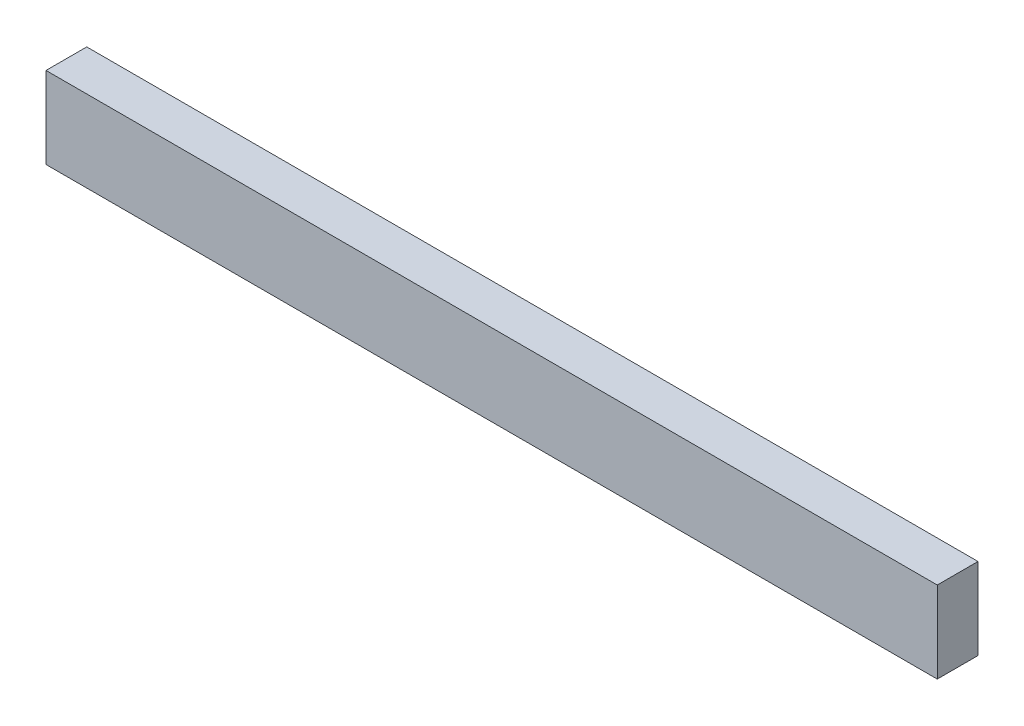
from build123d import *

# Parameters (mm, degrees)
SKETCH1_W           = 555.625
SKETCH1_H           = 50.8
BOSS_EXTRUDE1_DEPTH = 25.4


with BuildPart() as part:
    # Sketch1 → Boss-Extrude1 (new body)
    with BuildSketch(Plane.XY):
        with Locations((277.8125, 25.4)):
            Rectangle(SKETCH1_W, SKETCH1_H)
    extrude(amount=BOSS_EXTRUDE1_DEPTH)


solid = part.part
